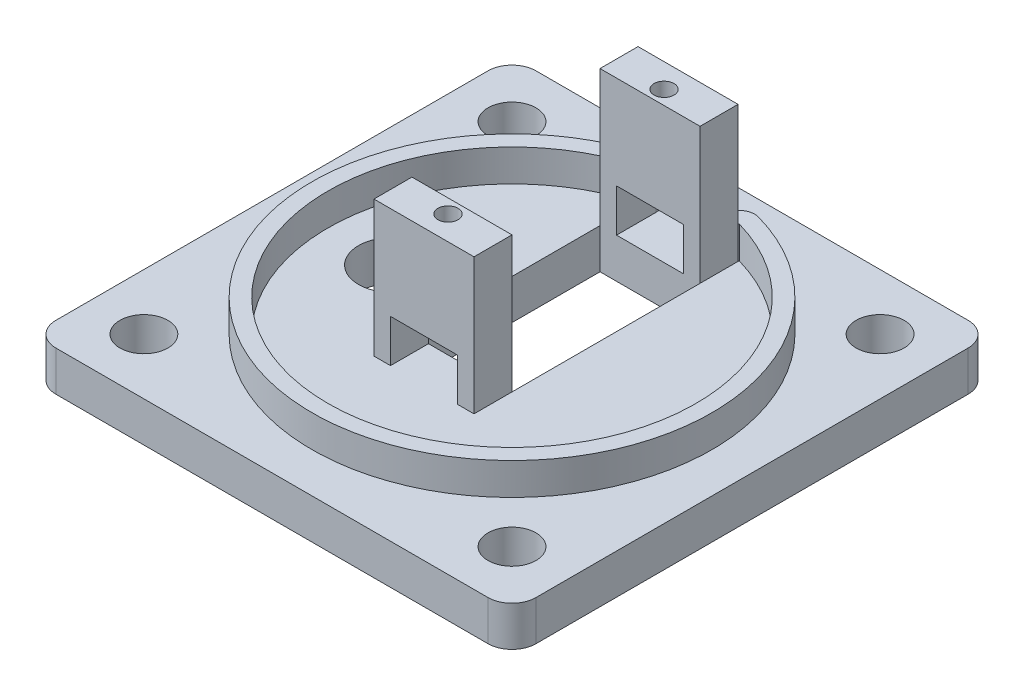
from build123d import *

# Parameters (mm, degrees)
SKETCH_1_R          = 3
SKETCH_1_W          = 12.5
SKETCH_1_H          = 23.5
EXTRUDE_1_DEPTH     = 5
SKETCH_2_W          = 12.5
SKETCH_2_H          = 4.75
SKETCH_2_R          = 1.25
EXTRUDE_2_DEPTH     = 17
SKETCH_4_R          = 25
EXTRUDE_7_DEPTH     = 4
SKETCH_5_W          = 8.371461974
SKETCH_5_H          = 5.334847295
CUT_EXTRUDE_1_DEPTH = 42
FILLET_1_R          = 2
SKETCH_6_R          = 4.21665728
CUT_EXTRUDE_2_DEPTH = 10


with BuildPart() as part:
    # 草图1 → 凸台-拉伸1 (new body)
    with BuildSketch(Plane(origin=(0, 0, 0), x_dir=(1, 0, 0), z_dir=(0, 1, 0))):
        with BuildLine():
            Line((27, 30), (-27, 30))
            ThreePointArc((-27, 30), (-29.121320344, 29.121320344), (-30, 27))
            Line((-30, 27), (-30, -27))
            ThreePointArc((-30, -27), (-29.121320344, -29.121320344), (-27, -30))
            Line((-27, -30), (27, -30))
            ThreePointArc((27, -30), (29.121320344, -29.121320344), (30, -27))
            Line((30, -27), (30, 27))
            ThreePointArc((30, 27), (29.121320344, 29.121320344), (27, 30))
        make_face()
        with Locations((-23, 23)):
            Circle(SKETCH_1_R, mode=Mode.SUBTRACT)
        with Locations((23, 23)):
            Circle(SKETCH_1_R, mode=Mode.SUBTRACT)
        with Locations((23, -23)):
            Circle(SKETCH_1_R, mode=Mode.SUBTRACT)
        with Locations((-23, -23)):
            Circle(SKETCH_1_R, mode=Mode.SUBTRACT)
        with Locations((0, 5.5)):
            Rectangle(SKETCH_1_W, SKETCH_1_H, mode=Mode.SUBTRACT)
    extrude(amount=EXTRUDE_1_DEPTH)

    # 草图2 → 凸台-拉伸2 (add)
    with BuildSketch(Plane(origin=(0, 5, 0), x_dir=(1, 0, 0), z_dir=(0, 1, 0))):
        with Locations((0, 19.625)):
            Rectangle(SKETCH_2_W, SKETCH_2_H)
        with Locations((0, 19)):
            Circle(SKETCH_2_R, mode=Mode.SUBTRACT)
        with Locations((0, -8.625)):
            Rectangle(SKETCH_2_W, SKETCH_2_H)
        with Locations((0, -8)):
            Circle(SKETCH_2_R, mode=Mode.SUBTRACT)
    extrude(amount=EXTRUDE_2_DEPTH)

    # 草图4 → 凸台-拉伸7 (add)
    with BuildSketch(Plane(origin=(0, 5, 0), x_dir=(1, 0, 0), z_dir=(0, 1, 0))):
        Circle(SKETCH_4_R)
        with BuildLine():
            Line((-6.285373074, 22.124513222), (-6.25, 22))
            Line((-6.25, 22), (6.25, 22))
            Line((6.25, 22), (6.285373074, 22.124513222))
            ThreePointArc((6.285373074, 22.124513222), (0, -23), (-6.285373074, 22.124513222))
        make_face(mode=Mode.SUBTRACT)
    extrude(amount=EXTRUDE_7_DEPTH)

    # 草图5 → 切除-拉伸1 (cut)
    with BuildSketch(Plane.XY.offset(11)):
        with Locations((0, 7.667423648)):
            Rectangle(SKETCH_5_W, SKETCH_5_H)
    extrude(amount=-CUT_EXTRUDE_1_DEPTH, mode=Mode.SUBTRACT)

    # 圆角1
    fillet_1_edges = [part.edges().sort_by_distance(p)[0] for p in [
        (-4.185730987, 7, -24.647102388),
        (4.185730987, 7, -24.647102388),
    ]]
    fillet(fillet_1_edges, radius=FILLET_1_R)

    # 草图6 → 切除-拉伸2 (cut)
    with BuildSketch(Plane(origin=(0, 5, 0), x_dir=(1, 0, 0), z_dir=(0, 1, 0))):
        with Locations((-14.961939604, 0)):
            Circle(SKETCH_6_R)
    extrude(amount=-CUT_EXTRUDE_2_DEPTH, mode=Mode.SUBTRACT)


solid = part.part
